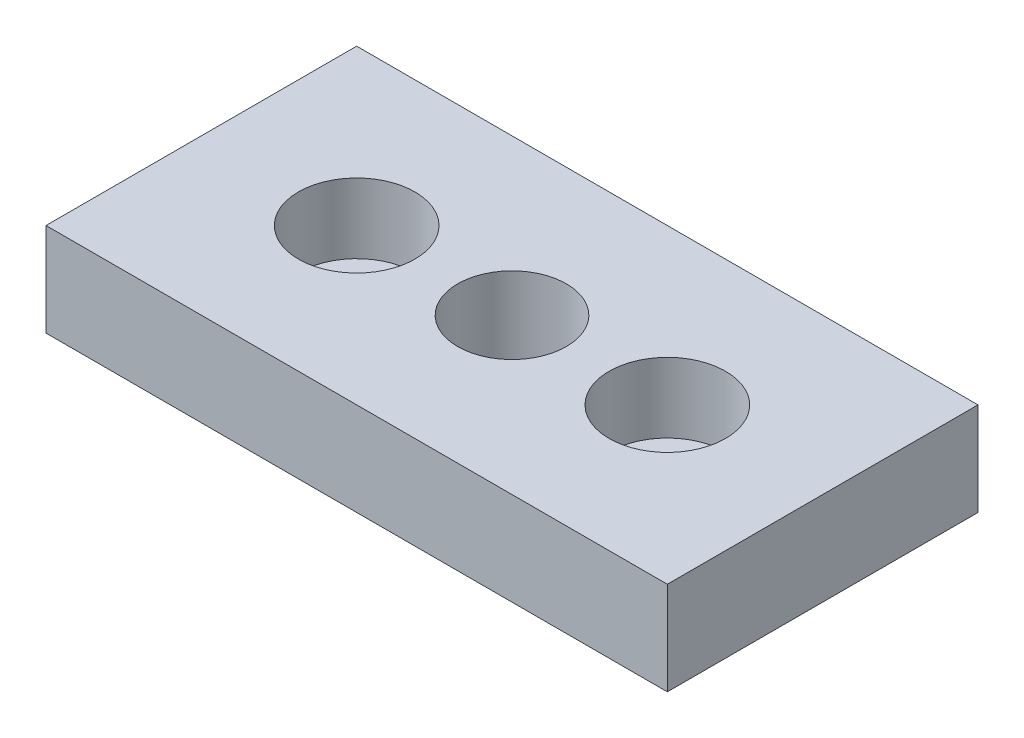
from build123d import *

# Parameters (mm, degrees)
SKETCH_1_W             = 80
SKETCH_1_H             = 40
EXTRUDE_1_DEPTH        = 12
HOLE_WIZARD_M161_D     = 14
HOLE_WIZARD_M161_DEPTH = 12


with BuildPart() as part:
    # Эскиз1 → Бобышка-Вытянуть1 (new body)
    with BuildSketch(Plane(origin=(0, 0, 0), x_dir=(1, 0, 0), z_dir=(0, 1, 0))):
        Rectangle(SKETCH_1_W, SKETCH_1_H)
    extrude(amount=EXTRUDE_1_DEPTH)

    # Эскиз2 → Вырез-Повернуть1 (revolve, cut)
    with BuildSketch(Plane.XY):
        Polygon((-27.5, 12), (-27.5, 3), (-24.5, 3), (-24.5, 0), (-20, 0), (-20, 12), align=None)
    cut_revolve_1 = revolve(axis=Axis((-20, 12, 0), (0, -1, 0)), mode=Mode.SUBTRACT)

    # Зеркальное отражение1: Вырез-Повернуть1 across plane
    add(cut_revolve_1.mirror(Plane(origin=(0, 0, 0), x_dir=(0, 0, 1), z_dir=(1, 0, 0))), mode=Mode.SUBTRACT)

    # Отверстие обработанное метчиком M161
    with Locations(Plane(origin=(0, 12, 0), x_dir=(1, 0, 0), z_dir=(0, 1, 0))):
        with Locations((0, 0)):
            Hole(HOLE_WIZARD_M161_D / 2, depth=HOLE_WIZARD_M161_DEPTH)


solid = part.part
